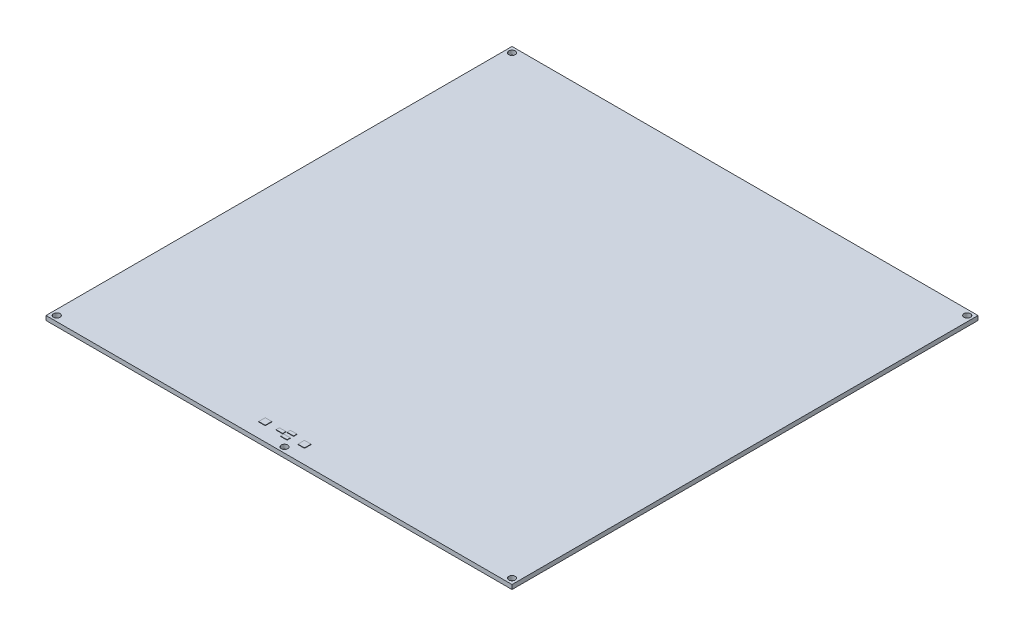
from build123d import *

# Parameters (mm, degrees)
CROQUIS1_W                    = 214
CROQUIS1_H                    = 214
SALIENTE_EXTRUIR1_DEPTH       = 2
CROQUIS2_W                    = 3
CROQUIS2_H                    = 3
SALIENTE_EXTRUIR2_DEPTH       = 0.2
CROQUIS3_W                    = 3
CROQUIS3_H                    = 3
SALIENTE_EXTRUIR3_DEPTH       = 0.2
CROQUIS4_W                    = 3
CROQUIS4_H                    = 1.5
SALIENTE_EXTRUIR4_DEPTH       = 0.2
CROQUIS5_W                    = 3
CROQUIS5_H                    = 1.5
SALIENTE_EXTRUIR5_DEPTH       = 0.2
CROQUIS6_W                    = 3
CROQUIS6_H                    = 1.5
SALIENTE_EXTRUIR6_DEPTH       = 0.2
DI_METRO_DE_TALADRO_3_0_3_1_D = 3


with BuildPart() as part:
    # Croquis1 → Saliente-Extruir1 (new body)
    with BuildSketch(Plane(origin=(0, 2, 0), x_dir=(1, 0, 0), z_dir=(0, 1, 0))):
        Rectangle(CROQUIS1_W, CROQUIS1_H)
    extrude(amount=-SALIENTE_EXTRUIR1_DEPTH)

    # Croquis2 → Saliente-Extruir2 (add)
    with BuildSketch(Plane(origin=(0, 2, 0), x_dir=(-1, 0, 0), z_dir=(0, 1, 0))):
        with Locations((-3.7, 99)):
            Rectangle(CROQUIS2_W, CROQUIS2_H)
    extrude(amount=SALIENTE_EXTRUIR2_DEPTH)

    # Croquis3 → Saliente-Extruir3 (add)
    with BuildSketch(Plane(origin=(0, 2, 0), x_dir=(-1, 0, 0), z_dir=(0, 1, 0))):
        with Locations((14.3, 99)):
            Rectangle(CROQUIS3_W, CROQUIS3_H)
    extrude(amount=SALIENTE_EXTRUIR3_DEPTH)

    # Croquis4 → Saliente-Extruir4 (add)
    with BuildSketch(Plane(origin=(0, 2, 0), x_dir=(-1, 0, 0), z_dir=(0, 1, 0))):
        with Locations((7.05, 99)):
            Rectangle(CROQUIS4_W, CROQUIS4_H)
    extrude(amount=SALIENTE_EXTRUIR4_DEPTH)

    # Croquis5 → Saliente-Extruir5 (add)
    with BuildSketch(Plane(origin=(0, 2, 0), x_dir=(-1, 0, 0), z_dir=(0, 1, 0))):
        with Locations((3.55, 97.5)):
            Rectangle(CROQUIS5_W, CROQUIS5_H)
    extrude(amount=SALIENTE_EXTRUIR5_DEPTH)

    # Croquis6 → Saliente-Extruir6 (add)
    with BuildSketch(Plane(origin=(0, 2, 0), x_dir=(-1, 0, 0), z_dir=(0, 1, 0))):
        with Locations((3.55, 100.5)):
            Rectangle(CROQUIS6_W, CROQUIS6_H)
    extrude(amount=SALIENTE_EXTRUIR6_DEPTH)

    # Diámetro de taladro Ø3.0 (3)1 (through all)
    with Locations(Plane(origin=(0, 2, 0), x_dir=(1, 0, 0), z_dir=(0, 1, 0))):
        with Locations((104.525132309, 104.525132309), (-104.525126266, -104.525126266), (104.474867691, -104.474867691), (-104.474867691, 104.474867691), (0, -104.474867691)):
            Hole(DI_METRO_DE_TALADRO_3_0_3_1_D / 2)


solid = part.part
